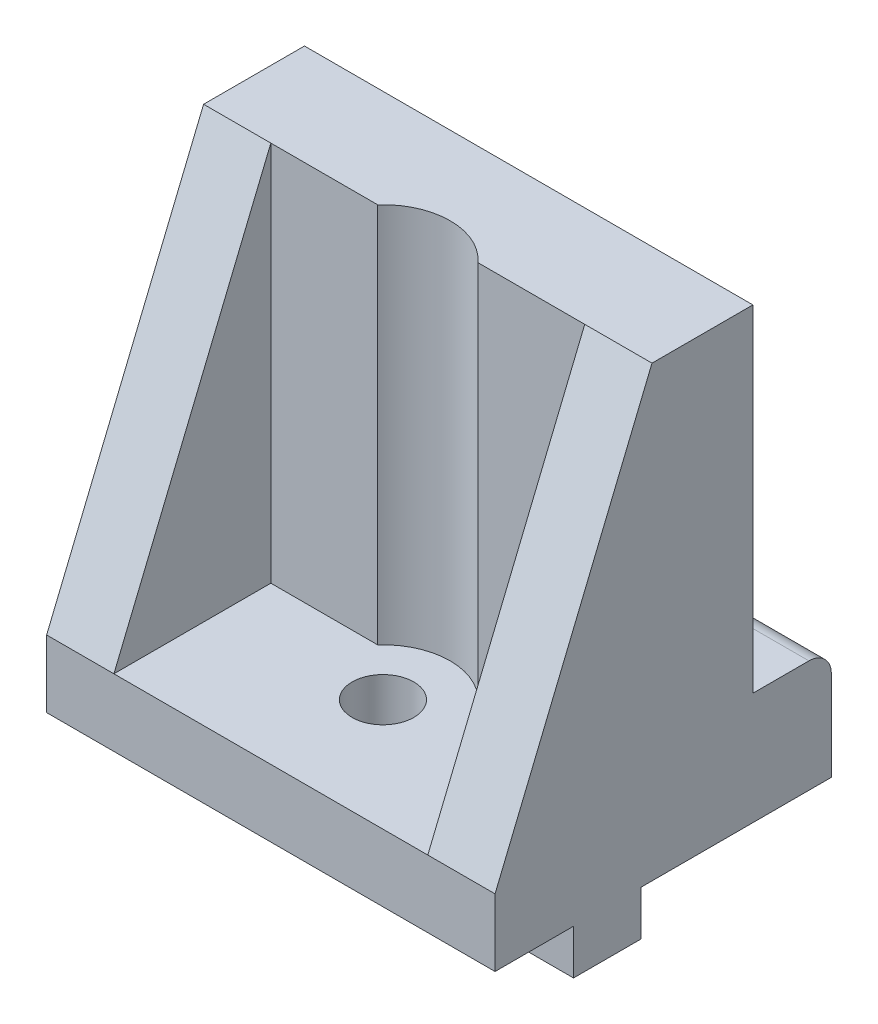
from build123d import *

# Parameters (mm, degrees)
CROQUIS1_W              = 40
CROQUIS1_H              = 40
SALIENTE_EXTRUIR1_DEPTH = 20
CROQUIS2_W              = 28
CROQUIS2_H              = 14
CORTAR_EXTRUIR1_DEPTH   = 34
CORTAR_EXTRUIR2_DEPTH   = 40
CROQUIS7_W              = 40
CROQUIS7_H              = 6
SALIENTE_EXTRUIR2_DEPTH = 1
CROQUIS8_R              = 2.75
CORTAR_EXTRUIR6_DEPTH   = 7
CROQUIS9_R              = 6
CORTAR_EXTRUIR7_DEPTH   = 34
CROQUIS10_W             = 10
CROQUIS10_H             = 6
SALIENTE_EXTRUIR3_DEPTH = 3
REDONDEO1_R             = 2
SALIENTE_EXTRUIR5_DEPTH = 40
REDONDEO2_R             = 2


with BuildPart() as part:
    # Croquis1 → Saliente-Extruir1 (new body)
    with BuildSketch(Plane.XY):
        with Locations((20, -20)):
            Rectangle(CROQUIS1_W, CROQUIS1_H)
    extrude(amount=SALIENTE_EXTRUIR1_DEPTH)

    # Croquis2 → Cortar-Extruir1 (cut)
    with BuildSketch(Plane(origin=(0, 0, 0), x_dir=(1, 0, 0), z_dir=(0, 1, 0))):
        with Locations((20, -13)):
            Rectangle(CROQUIS2_W, CROQUIS2_H)
    extrude(amount=-CORTAR_EXTRUIR1_DEPTH, mode=Mode.SUBTRACT)

    # Croquis3 → Cortar-Extruir2 (cut)
    with BuildSketch(Plane.ZY):
        Polygon((20, 0), (20, -34), (6, 0), align=None)
    extrude(amount=-CORTAR_EXTRUIR2_DEPTH, mode=Mode.SUBTRACT)

    # Croquis7 → Saliente-Extruir2 (add)
    with BuildSketch(Plane.XZ.offset(40)):
        with Locations((20, 10)):
            Rectangle(CROQUIS7_W, CROQUIS7_H)
    extrude(amount=SALIENTE_EXTRUIR2_DEPTH)

    # Croquis8 → Cortar-Extruir6 (cut)
    with BuildSketch(Plane.XZ.offset(41)):
        with Locations((20, 10)):
            Circle(CROQUIS8_R)
    extrude(amount=-CORTAR_EXTRUIR6_DEPTH, mode=Mode.SUBTRACT)

    # Croquis9 → Cortar-Extruir7 (cut)
    with BuildSketch(Plane(origin=(0, -34, 0), x_dir=(1, 0, 0), z_dir=(0, 1, 0))):
        with Locations((20, -10)):
            Circle(CROQUIS9_R)
    extrude(amount=CORTAR_EXTRUIR7_DEPTH, mode=Mode.SUBTRACT)

    # Croquis10 → Saliente-Extruir3 (add)
    with BuildSketch(Plane.XZ.offset(41)):
        with Locations((5, 10)):
            Rectangle(CROQUIS10_W, CROQUIS10_H)
        with Locations((35, 10)):
            Rectangle(CROQUIS10_W, CROQUIS10_H)
    extrude(amount=SALIENTE_EXTRUIR3_DEPTH)

    # Redondeo1
    redondeo1_edges = [part.edges().sort_by_distance(p)[0] for p in [
        (10, -41, 10),
        (30, -41, 10),
    ]]
    fillet(redondeo1_edges, radius=REDONDEO1_R)

    # Croquis12 → Saliente-Extruir5 (add)
    with BuildSketch(Plane.ZY):
        Polygon((0, -40), (-10, -40), (-10, -30), (-3, -30), (-3, 0), (0, 0), align=None)
    extrude(amount=-SALIENTE_EXTRUIR5_DEPTH)

    # Redondeo2
    redondeo2_edges = [part.edges().sort_by_distance(p)[0] for p in [
        (20, -30, -10),
    ]]
    fillet(redondeo2_edges, radius=REDONDEO2_R)


solid = part.part
